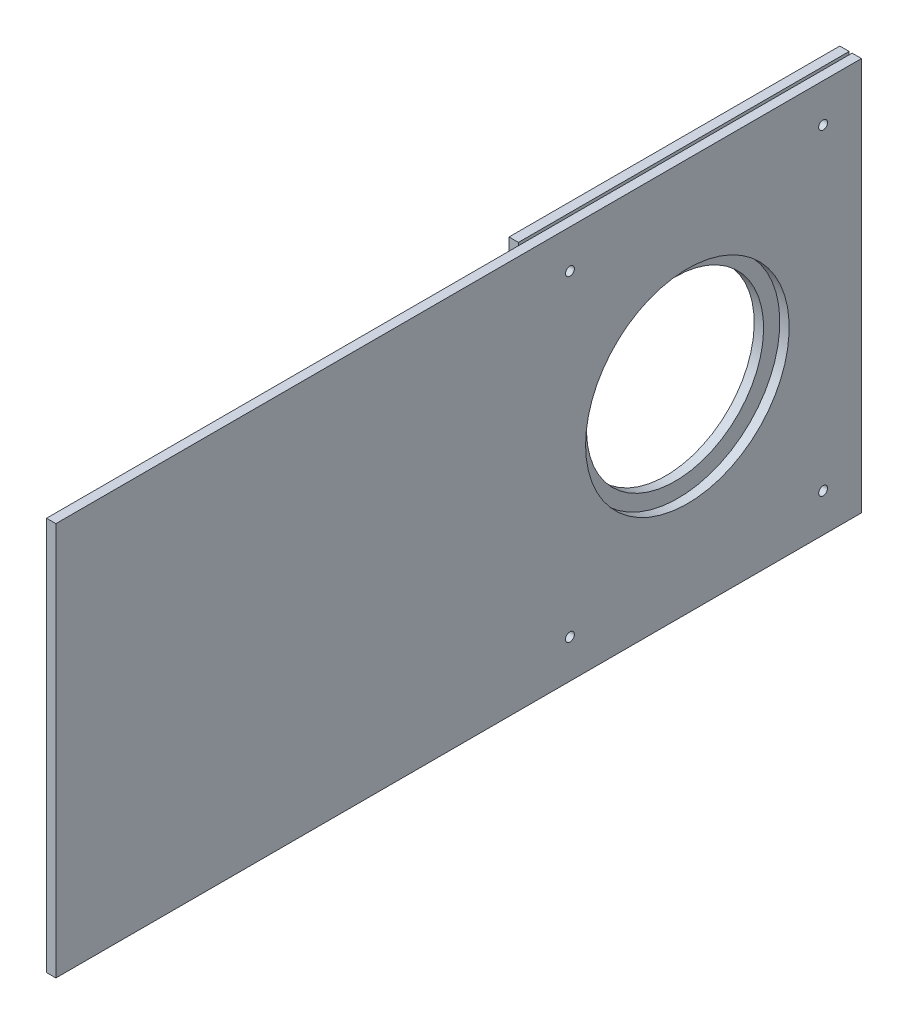
from build123d import *

# Parameters (mm, degrees)
SKETCH1_W               = 3.175
SKETCH1_H               = 133.35
BOSS_EXTRUDE1_DEPTH     = 273
BOSS_EXTRUDE1_2_DEPTH   = 273
SKETCH3_R               = 30
CUT_EXTRUDE2_DEPTH      = 295
SKETCH2_R               = 34.5
CUT_EXTRUDE3_DEPTH      = 100
CUT_EXTRUDE3_DEPTH_BACK = 13
SKETCH4_R               = 1.5
CUT_EXTRUDE4_DEPTH      = 3
CUT_EXTRUDE4_DEPTH_BACK = 63
SKETCH5_W               = 164.64534511
SKETCH5_H               = 137.520906048
CUT_EXTRUDE5_DEPTH      = 11
CUT_EXTRUDE5_DEPTH_BACK = 4


with BuildPart() as part:
    # Sketch1 → Boss-Extrude1 (new body)
    with BuildSketch(Plane.XY):
        with Locations((-142.822089486, 0)):
            Rectangle(SKETCH1_W, SKETCH1_H)
    extrude(amount=BOSS_EXTRUDE1_DEPTH)

    # Sketch2 → Cut-Extrude3 (cut, two sides)
    with BuildSketch(Plane.ZY.offset(144.409589486)) as cut_extrude3_sk:
        with Locations((59, 0)):
            Circle(SKETCH2_R)
    extrude(amount=CUT_EXTRUDE3_DEPTH, mode=Mode.SUBTRACT)
    extrude(cut_extrude3_sk.sketch, amount=-CUT_EXTRUDE3_DEPTH_BACK, mode=Mode.SUBTRACT)


with BuildPart() as body_2:
    # Sketch1 → Boss-Extrude1 2 (new body)
    with BuildSketch(Plane.XY):
        with Locations((-146.997089486, 0)):
            Rectangle(SKETCH1_W, SKETCH1_H)
    extrude(amount=BOSS_EXTRUDE1_2_DEPTH)

    # Sketch3 → Cut-Extrude2 (cut)
    with BuildSketch(Plane(origin=(-145.409589486, 0, 0), x_dir=(0, 0, -1), z_dir=(1, 0, 0))):
        with Locations((-59, 0)):
            Circle(SKETCH3_R)
    extrude(amount=-CUT_EXTRUDE2_DEPTH, mode=Mode.SUBTRACT)


with BuildPart() as cut_extrude4_tool:
    # Sketch4 → Cut-Extrude4 (new body, two sides)
    with BuildSketch(Plane.ZY.offset(148.584589486)) as cut_extrude4_sk:
        with Locations((13, -53.675)):
            Circle(SKETCH4_R)
        with Locations((13, 53.675)):
            Circle(SKETCH4_R)
        with Locations((98.797029703, -53.675)):
            Circle(SKETCH4_R)
        with Locations((98.797029703, 53.675)):
            Circle(SKETCH4_R)
    extrude(amount=CUT_EXTRUDE4_DEPTH)
    extrude(cut_extrude4_sk.sketch, amount=-CUT_EXTRUDE4_DEPTH_BACK)


with BuildPart() as part_1:
    add(part.part)

    # Cut-Extrude4: cut by cut_extrude4_tool
    add(cut_extrude4_tool.part, mode=Mode.SUBTRACT)


with BuildPart() as body_2_1:
    add(body_2.part)

    # Cut-Extrude4: cut by cut_extrude4_tool
    add(cut_extrude4_tool.part, mode=Mode.SUBTRACT)

    # Sketch5 → Cut-Extrude5 (cut, two sides)
    with BuildSketch(Plane.ZY.offset(148.584589486)) as cut_extrude5_sk:
        with Locations((194.410677399, -0.406866586)):
            Rectangle(SKETCH5_W, SKETCH5_H)
    extrude(amount=CUT_EXTRUDE5_DEPTH, mode=Mode.SUBTRACT)
    extrude(cut_extrude5_sk.sketch, amount=-CUT_EXTRUDE5_DEPTH_BACK, mode=Mode.SUBTRACT)


solid = Compound([part_1.part, body_2_1.part])
